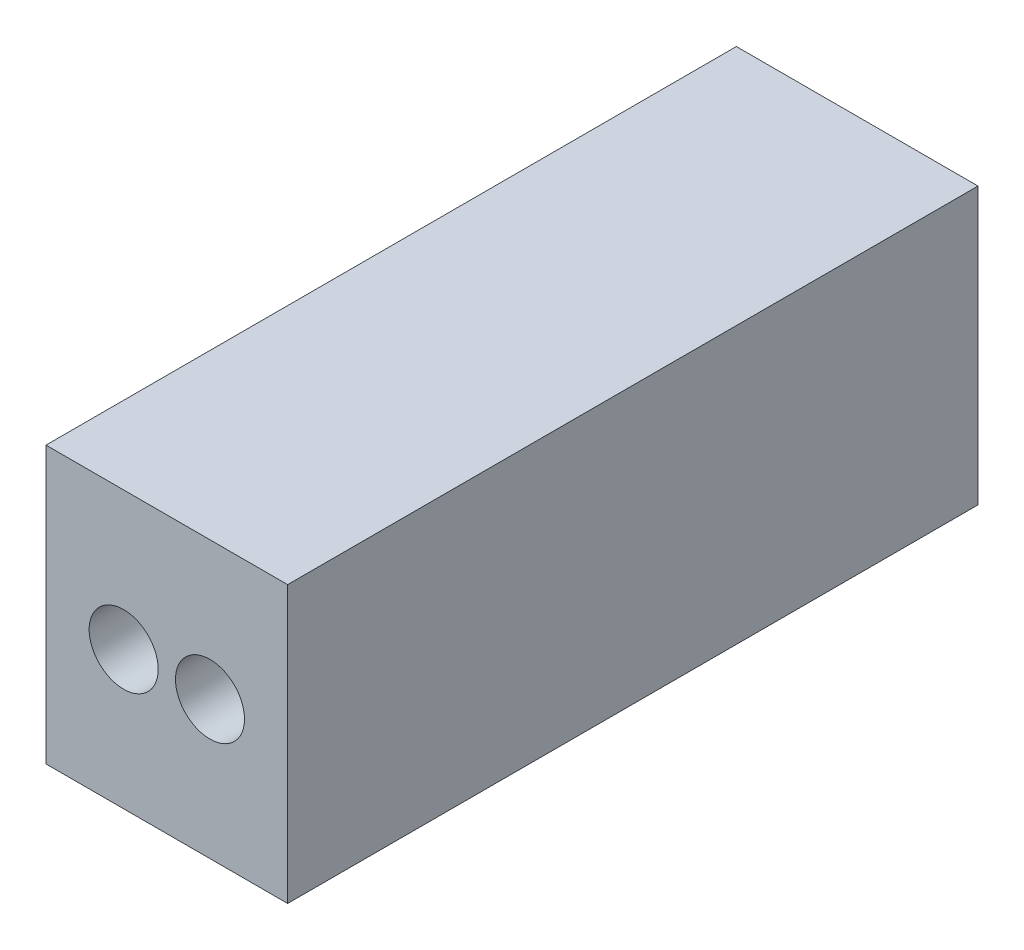
from build123d import *

# Parameters (mm, degrees)
SKETCH2_W           = 3.5
SKETCH2_H           = 4
BOSS_EXTRUDE1_DEPTH = 10
SKETCH3_R           = 0.5
CUT_EXTRUDE1_DEPTH  = 5


with BuildPart() as part:
    # Sketch2 → Boss-Extrude1 (new body)
    with BuildSketch(Plane.XY):
        with Locations((1.75, 2)):
            Rectangle(SKETCH2_W, SKETCH2_H)
    extrude(amount=BOSS_EXTRUDE1_DEPTH)

    # Sketch3 → Cut-Extrude1 (cut)
    with BuildSketch(Plane.XY.offset(10)):
        with Locations((1.125, 2)):
            Circle(SKETCH3_R)
        with Locations((2.375, 2)):
            Circle(SKETCH3_R)
    extrude(amount=-CUT_EXTRUDE1_DEPTH, mode=Mode.SUBTRACT)


solid = part.part
